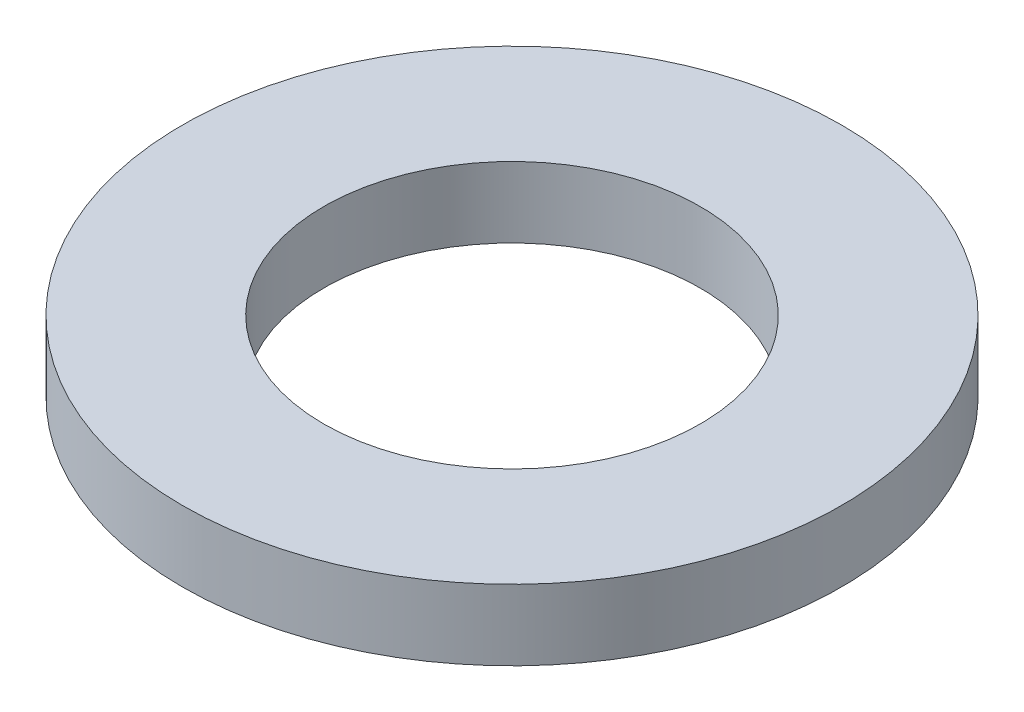
from build123d import *

# Parameters (mm, degrees)
CROQUIS1_R              = 14
CROQUIS1_R_2            = 8
SALIENTE_EXTRUIR1_DEPTH = 3


with BuildPart() as part:
    # Croquis1 → Saliente-Extruir1 (new body)
    with BuildSketch(Plane(origin=(0, 0, 0), x_dir=(1, 0, 0), z_dir=(0, 1, 0))):
        Circle(CROQUIS1_R)
        Circle(CROQUIS1_R_2, mode=Mode.SUBTRACT)
    extrude(amount=SALIENTE_EXTRUIR1_DEPTH)


solid = part.part
